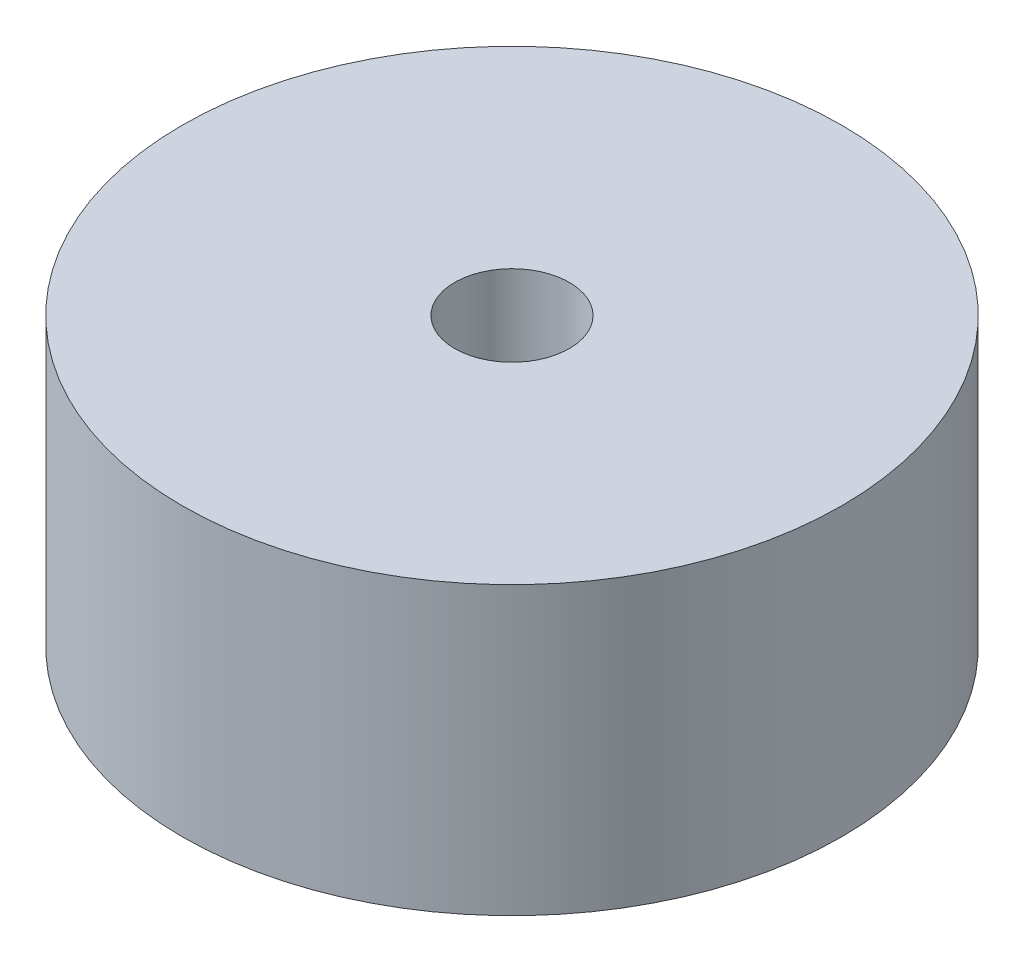
from build123d import *

# Parameters (mm, degrees)
SKETCH1_R                 = 23
BOSS_EXTRUDE1_DEPTH       = 20
SKETCH2_R                 = 4
CUT_EXTRUDE1_DEPTH        = 20
M3X0_5_TAPPED_HOLE1_D     = 2.5
M3X0_5_TAPPED_HOLE1_DEPTH = 6.5
M3X0_5_TAPPED_HOLE1_TIP   = 0.751075774


with BuildPart() as part:
    # Sketch1 → Boss-Extrude1 (new body)
    with BuildSketch(Plane(origin=(0, 0, 0), x_dir=(1, 0, 0), z_dir=(0, 1, 0))):
        Circle(SKETCH1_R)
    extrude(amount=BOSS_EXTRUDE1_DEPTH)

    # Sketch2 → Cut-Extrude1 (cut)
    with BuildSketch(Plane(origin=(0, 20, 0), x_dir=(1, 0, 0), z_dir=(0, 1, 0))):
        Circle(SKETCH2_R)
    extrude(amount=-CUT_EXTRUDE1_DEPTH, mode=Mode.SUBTRACT)

    # M3x0.5 Tapped Hole1
    with Locations(Plane(origin=(0, 0, 0), x_dir=(-1, 0, 0), z_dir=(0, -1, 0))):
        with Locations((6.717514421, 6.717514421), (-7.5, 0), (7.5, 0), (0, 7.5), (0, -7.5), (-6.717514421, 6.717514421), (-6.717514421, -6.717514421), (6.717514421, -6.717514421)):
            Hole(M3X0_5_TAPPED_HOLE1_D / 2, depth=M3X0_5_TAPPED_HOLE1_DEPTH)
            with Locations((0, 0, -(M3X0_5_TAPPED_HOLE1_DEPTH + M3X0_5_TAPPED_HOLE1_TIP / 2))):  # 118° drill point
                Cone(0, M3X0_5_TAPPED_HOLE1_D / 2, M3X0_5_TAPPED_HOLE1_TIP, mode=Mode.SUBTRACT)


solid = part.part
